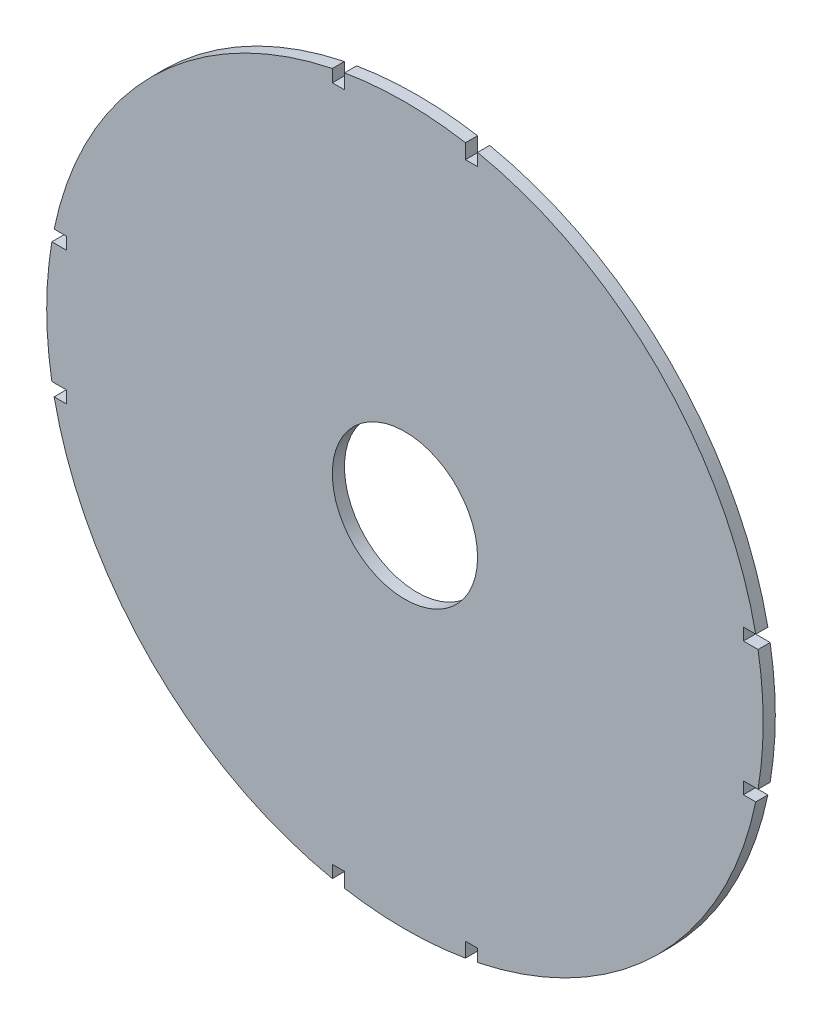
from build123d import *

# Parameters (mm, degrees)
SKETCH1_R           = 19.05
BOSS_EXTRUDE1_DEPTH = 3.175


with BuildPart() as part:
    # Sketch1 → Boss-Extrude1 (new body)
    with BuildSketch(Plane.XY):
        with BuildLine():
            Line((-19.05, -92.029005754), (-19.05, -88.774236431))
            Line((-19.05, -88.774236431), (-15.875, -88.774236431))
            Line((-15.875, -88.774236431), (-15.875, -92.629502725))
            ThreePointArc((-15.875, -92.629502725), (0, -93.98), (15.875, -92.629502725))
            Line((15.875, -92.629502725), (15.875, -88.774236431))
            Line((15.875, -88.774236431), (19.05, -88.774236431))
            Line((19.05, -88.774236431), (19.05, -92.029005754))
            ThreePointArc((19.05, -92.029005754), (20.640594227, -91.685365626), (22.225, -91.314236431))
            ThreePointArc((22.225, -91.314236431), (67.594559133, -65.29330728), (92.029005754, -19.05))
            Line((92.029005754, -19.05), (88.774236431, -19.05))
            Line((88.774236431, -19.05), (88.774236431, -15.875))
            Line((88.774236431, -15.875), (92.629502725, -15.875))
            ThreePointArc((92.629502725, -15.875), (93.98, 0), (92.629502725, 15.875))
            Line((92.629502725, 15.875), (88.774236431, 15.875))
            Line((88.774236431, 15.875), (88.774236431, 19.05))
            Line((88.774236431, 19.05), (92.029005754, 19.05))
            ThreePointArc((92.029005754, 19.05), (66.453895296, 66.453895296), (19.05, 92.029005754))
            Line((19.05, 92.029005754), (19.05, 88.774236431))
            Line((19.05, 88.774236431), (15.875, 88.774236431))
            Line((15.875, 88.774236431), (15.875, 92.629502725))
            ThreePointArc((15.875, 92.629502725), (0, 93.98), (-15.875, 92.629502725))
            Line((-15.875, 92.629502725), (-15.875, 88.774236431))
            Line((-15.875, 88.774236431), (-19.05, 88.774236431))
            Line((-19.05, 88.774236431), (-19.05, 92.029005754))
            ThreePointArc((-19.05, 92.029005754), (-20.640594227, 91.685365626), (-22.225, 91.314236431))
            ThreePointArc((-22.225, 91.314236431), (-66.453895296, 66.453895296), (-91.314236431, 22.225))
            ThreePointArc((-91.314236431, 22.225), (-91.685365626, 20.640594227), (-92.029005754, 19.05))
            Line((-92.029005754, 19.05), (-88.774236431, 19.05))
            Line((-88.774236431, 19.05), (-88.774236431, 15.875))
            Line((-88.774236431, 15.875), (-92.629502725, 15.875))
            ThreePointArc((-92.629502725, 15.875), (-93.98, 0), (-92.629502725, -15.875))
            Line((-92.629502725, -15.875), (-88.774236431, -15.875))
            Line((-88.774236431, -15.875), (-88.774236431, -19.05))
            Line((-88.774236431, -19.05), (-92.029005754, -19.05))
            ThreePointArc((-92.029005754, -19.05), (-66.453895296, -66.453895296), (-19.05, -92.029005754))
        make_face()
        Circle(SKETCH1_R, mode=Mode.SUBTRACT)
    extrude(amount=BOSS_EXTRUDE1_DEPTH)


solid = part.part
